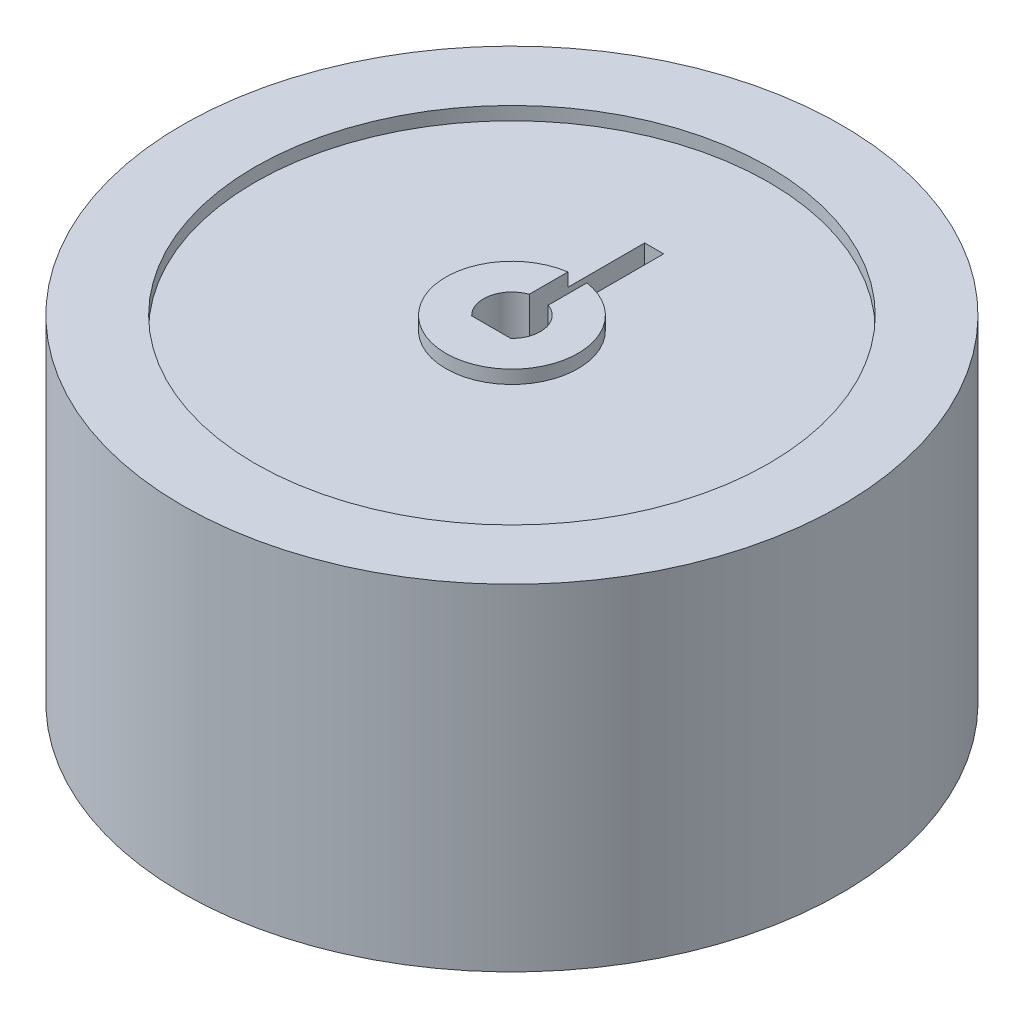
from build123d import *

# Parameters (mm, degrees)
SKETCH1_R           = 17.375
BOSS_EXTRUDE1_DEPTH = 17.7
SKETCH3_R           = 13.545
CUT_EXTRUDE1_DEPTH  = 0.7
SKETCH4_R           = 3.485
BOSS_EXTRUDE2_DEPTH = 0.7
CUT_EXTRUDE2_DEPTH  = 17.7
SKETCH6_W           = 1
SKETCH6_H           = 6.085786438
CUT_EXTRUDE3_DEPTH  = 17.7


with BuildPart() as part:
    # Sketch1 → Boss-Extrude1 (new body)
    with BuildSketch(Plane(origin=(0, 0, 0), x_dir=(1, 0, 0), z_dir=(0, 1, 0))):
        Circle(SKETCH1_R)
    extrude(amount=BOSS_EXTRUDE1_DEPTH)

    # Sketch3 → Cut-Extrude1 (cut)
    with BuildSketch(Plane(origin=(0, 17.7, 0), x_dir=(1, 0, 0), z_dir=(0, 1, 0))):
        Circle(SKETCH3_R)
    extrude(amount=-CUT_EXTRUDE1_DEPTH, mode=Mode.SUBTRACT)

    # Sketch4 → Boss-Extrude2 (add)
    with BuildSketch(Plane(origin=(0, 17, 0), x_dir=(1, 0, 0), z_dir=(0, 1, 0))):
        Circle(SKETCH4_R)
    extrude(amount=BOSS_EXTRUDE2_DEPTH)

    # Sketch5 → Cut-Extrude2 (cut)
    with BuildSketch(Plane(origin=(0, 17.7, 0), x_dir=(1, 0, 0), z_dir=(0, 1, 0))):
        with BuildLine():
            Line((-1.030485323, -1.09), (1.030485323, -1.09))
            ThreePointArc((1.030485323, -1.09), (0, 1.5), (-1.030485323, -1.09))
        make_face()
    extrude(amount=-CUT_EXTRUDE2_DEPTH, mode=Mode.SUBTRACT)

    # Sketch6 → Cut-Extrude3 (cut)
    with BuildSketch(Plane(origin=(0, 17.7, 0), x_dir=(1, 0, 0), z_dir=(0, 1, 0))):
        with Locations((0, 4.457106781)):
            Rectangle(SKETCH6_W, SKETCH6_H)
    extrude(amount=-CUT_EXTRUDE3_DEPTH, mode=Mode.SUBTRACT)


solid = part.part
